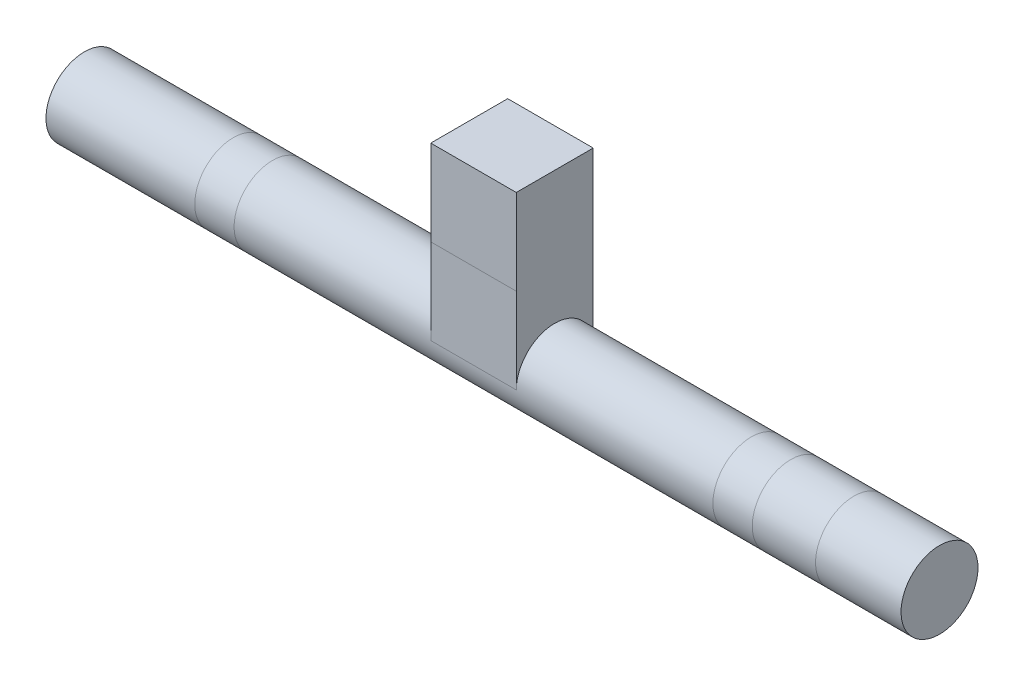
from build123d import *

# Parameters (mm, degrees)
ESQUISSE1_R        = 45
BOSS_EXTRU_1_DEPTH = 500
ESQUISSE2_W        = 90
ESQUISSE2_H        = 200
BOSS_EXTRU_2_DEPTH = 50


with BuildPart() as part:
    # Esquisse1 → Boss.-Extru.1 (new body, symmetric)
    with BuildSketch(Plane(origin=(0, 0, 0), x_dir=(0, 0, -1), z_dir=(1, 0, 0))):
        Circle(ESQUISSE1_R)
    extrude(amount=BOSS_EXTRU_1_DEPTH, both=True)

    # Esquisse2 → Boss.-Extru.2 (add, symmetric)
    with BuildSketch(Plane(origin=(0, 0, 0), x_dir=(0, 0, -1), z_dir=(1, 0, 0))):
        with Locations((0, 100)):
            Rectangle(ESQUISSE2_W, ESQUISSE2_H)
    extrude(amount=BOSS_EXTRU_2_DEPTH, both=True)


solid = part.part
